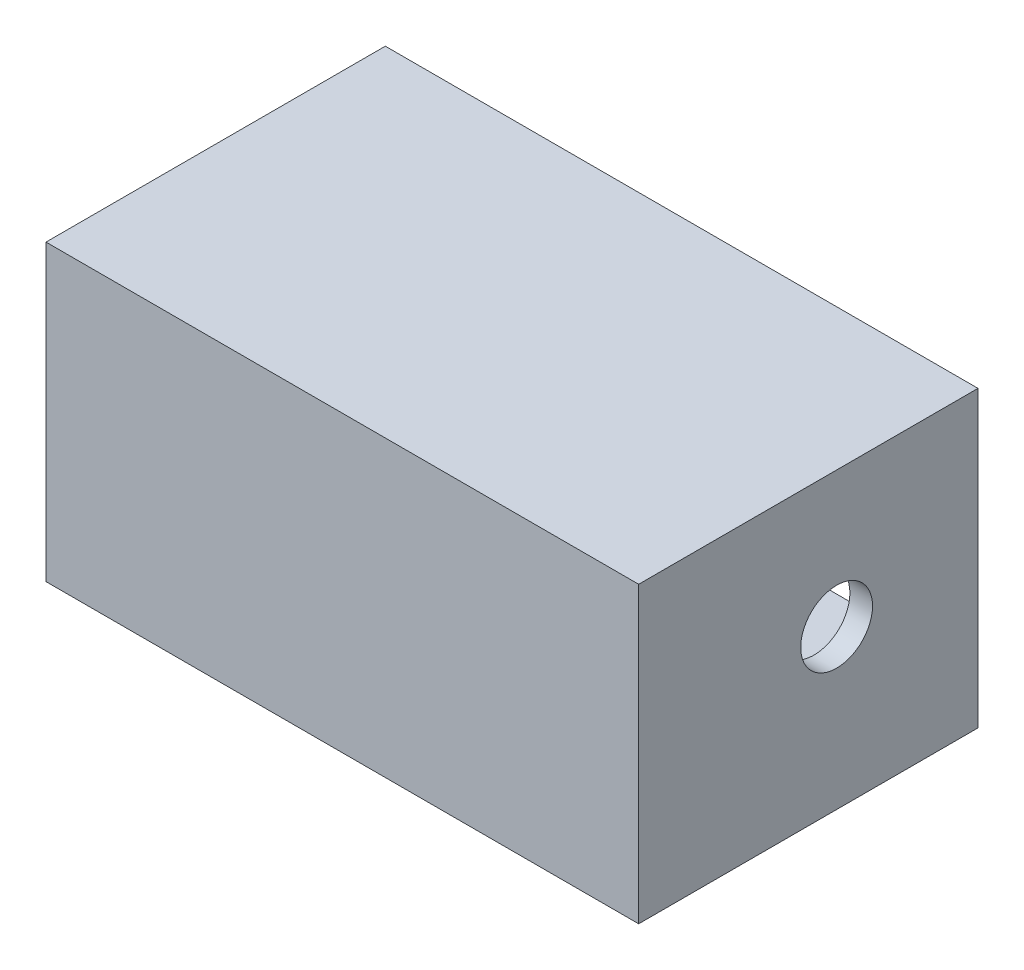
from build123d import *

# Parameters (mm, degrees)
SKETCH1_W           = 262
SKETCH1_H           = 150
BOSS_EXTRUDE1_DEPTH = 20
BOSS_EXTRUDE2_DEPTH = 100
SKETCH3_R           = 14.2875
CUT_EXTRUDE1_DEPTH  = 11
SKETCH4_R           = 15.875
CUT_EXTRUDE2_DEPTH  = 11
SKETCH5_W           = 262
SKETCH5_H           = 150
BOSS_EXTRUDE4_DEPTH = 10


with BuildPart() as part:
    # Sketch1 → Boss-Extrude1 (new body)
    with BuildSketch(Plane(origin=(0, 0, 0), x_dir=(1, 0, 0), z_dir=(0, 1, 0))):
        with Locations((131, 75)):
            Rectangle(SKETCH1_W, SKETCH1_H)
    extrude(amount=BOSS_EXTRUDE1_DEPTH)

    # Sketch2 → Boss-Extrude2 (add)
    with BuildSketch(Plane(origin=(0, 20, 0), x_dir=(1, 0, 0), z_dir=(0, 1, 0))):
        Polygon((0, 0), (262, 0), (262, 150), (252, 150), (252, 10), (10, 10), (10, 150), (0, 150), align=None)
    extrude(amount=BOSS_EXTRUDE2_DEPTH)

    # Sketch3 → Cut-Extrude1 (cut, through all)
    with BuildSketch(Plane(origin=(10, 0, 0), x_dir=(0, 0, -1), z_dir=(1, 0, 0))):
        with Locations((87.5, 70)):
            Circle(SKETCH3_R)
    extrude(amount=-CUT_EXTRUDE1_DEPTH, mode=Mode.SUBTRACT)

    # Sketch4 → Cut-Extrude2 (cut, through all)
    with BuildSketch(Plane(origin=(252, 0, 0), x_dir=(0, 0, -1), z_dir=(1, 0, 0))):
        with Locations((87.5, 70)):
            Circle(SKETCH4_R)
    extrude(amount=CUT_EXTRUDE2_DEPTH, mode=Mode.SUBTRACT)

    # Sketch5 → Boss-Extrude4 (add)
    with BuildSketch(Plane(origin=(0, 120, 0), x_dir=(1, 0, 0), z_dir=(0, 1, 0))):
        with Locations((131, 75)):
            Rectangle(SKETCH5_W, SKETCH5_H)
    extrude(amount=BOSS_EXTRUDE4_DEPTH)


solid = part.part
